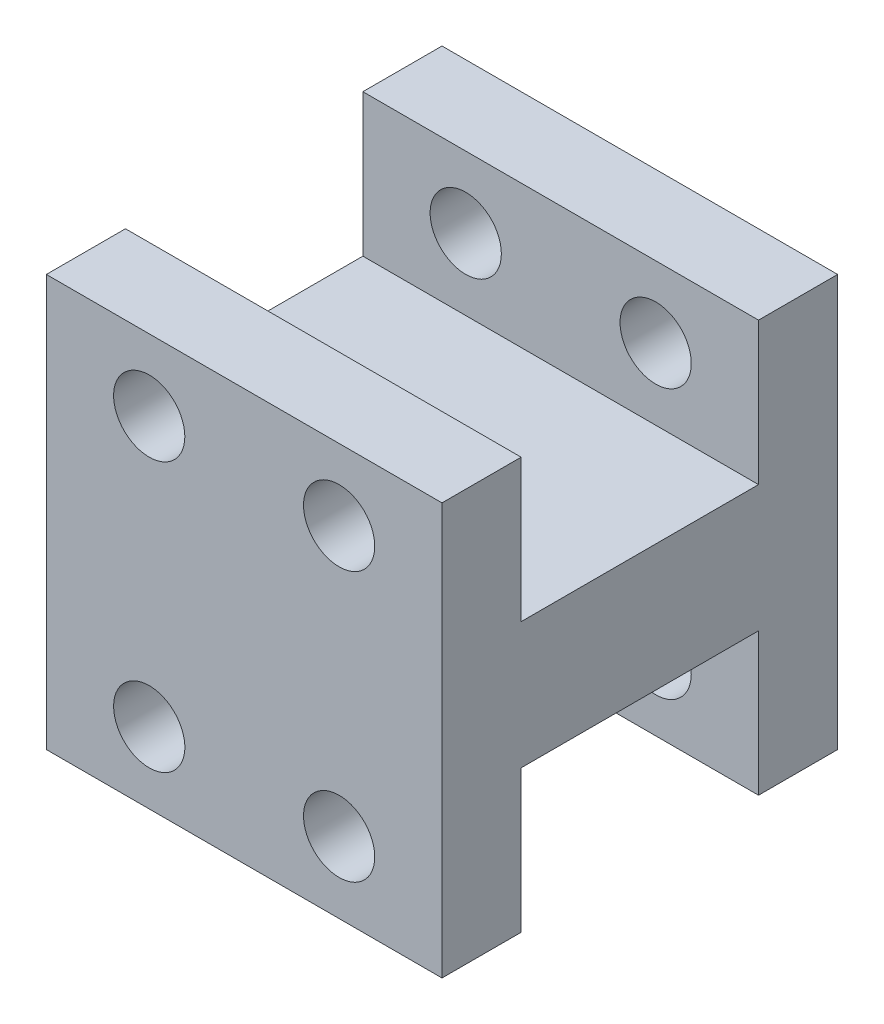
from build123d import *

# Parameters (mm, degrees)
SKETCH_1_W          = 25
SKETCH_1_H          = 50
EXTRUDE_1_DEPTH     = 5
SKETCH_2_R          = 2.25
CUT_EXTRUDE_1_DEPTH = 20
SKETCH_3_W          = 25
SKETCH_3_H          = 8
EXTRUDE_2_DEPTH     = 15
SKETCH_4_W          = 25
SKETCH_4_H          = 26
EXTRUDE_3_DEPTH     = 5
SKETCH_5_R          = 2.25
CUT_EXTRUDE_2_DEPTH = 5
SKETCH_6_W          = 25
SKETCH_6_H          = 50
CUT_EXTRUDE_3_DEPTH = 5


with BuildPart() as part:
    # 草图1 → 凸台-拉伸1 (new body)
    with BuildSketch(Plane.XY):
        with Locations((12.5, 25)):
            Rectangle(SKETCH_1_W, SKETCH_1_H)
    extrude(amount=EXTRUDE_1_DEPTH)

    # 草图2 → 切除-拉伸1 (cut)
    with BuildSketch(Plane.XY.offset(5)):
        with Locations((12.5, 7.5)):
            Circle(SKETCH_2_R)
        with Locations((12.5, 42.5)):
            Circle(SKETCH_2_R)
    extrude(amount=-CUT_EXTRUDE_1_DEPTH, mode=Mode.SUBTRACT)

    # 草图3 → 凸台-拉伸2 (add)
    with BuildSketch(Plane.XY.offset(5)):
        with Locations((12.5, 25)):
            Rectangle(SKETCH_3_W, SKETCH_3_H)
    extrude(amount=EXTRUDE_2_DEPTH)

    # 草图4 → 凸台-拉伸3 (add)
    with BuildSketch(Plane.XY.offset(20)):
        with Locations((12.5, 25)):
            Rectangle(SKETCH_4_W, SKETCH_4_H)
    extrude_3 = extrude(amount=EXTRUDE_3_DEPTH)

    # 草图5 → 切除-拉伸2 (cut)
    with BuildSketch(Plane(origin=(0, 0, 20), x_dir=(-1, 0, 0), z_dir=(0, 0, -1))):
        with Locations((-18.5, 33.5)):
            Circle(SKETCH_5_R)
        with Locations((-6.5, 33.5)):
            Circle(SKETCH_5_R)
        with Locations((-6.5, 16.5)):
            Circle(SKETCH_5_R)
        with Locations((-18.5, 16.5)):
            Circle(SKETCH_5_R)
    cut_extrude_2 = extrude(amount=-CUT_EXTRUDE_2_DEPTH, mode=Mode.SUBTRACT)

    # 草图6 → 切除-拉伸3 (cut)
    with BuildSketch(Plane(origin=(0, 0, 0), x_dir=(-1, 0, 0), z_dir=(0, 0, -1))):
        with Locations((-12.5, 25)):
            Rectangle(SKETCH_6_W, SKETCH_6_H)
    extrude(amount=-CUT_EXTRUDE_3_DEPTH, mode=Mode.SUBTRACT)

    # 镜向1: 凸台-拉伸3, 切除-拉伸2 across plane
    add(extrude_3.mirror(Plane(origin=(0, 0, 12.5), x_dir=(1, 0, 0), z_dir=(0, 0, -1))))
    add(cut_extrude_2.mirror(Plane(origin=(0, 0, 12.5), x_dir=(1, 0, 0), z_dir=(0, 0, -1))), mode=Mode.SUBTRACT)


solid = part.part
